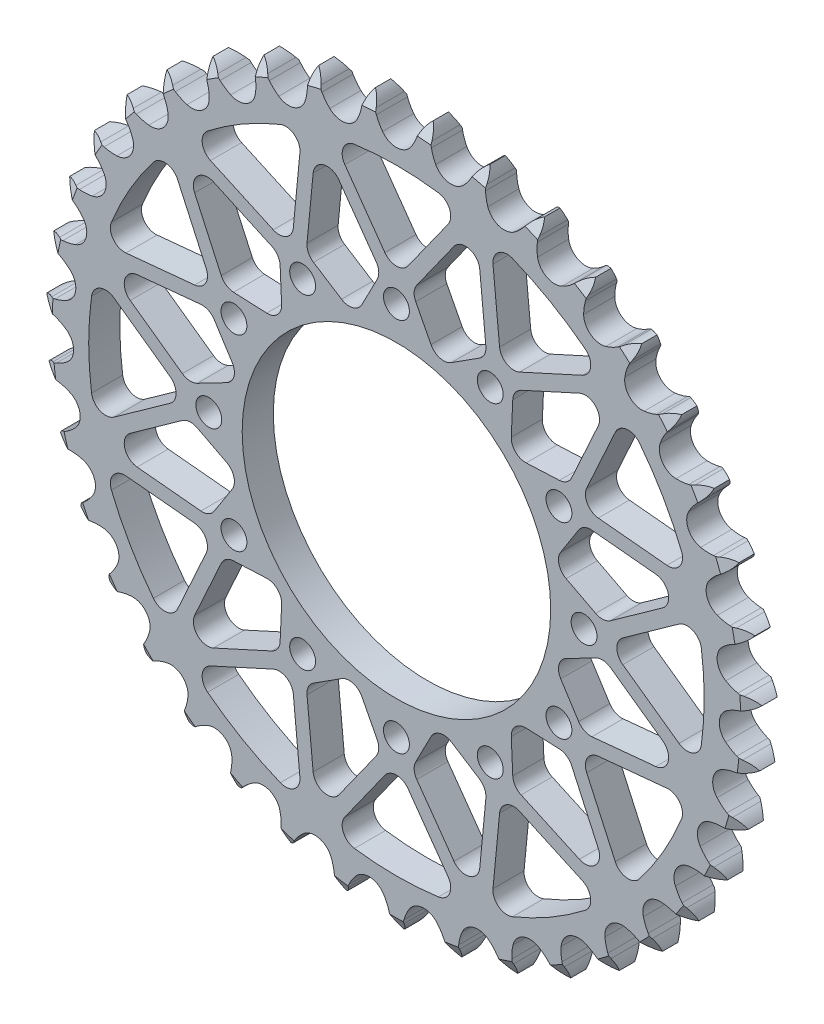
from build123d import *

# Parameters (mm, degrees)
EXTRUSION_DEPTH          = 7.2136
SKETCH1_R                = 35.764294032
CUT_EXTRUDE_DEPTH        = 1
CUT_EXTRUDE_DEPTH_BACK   = 8.2136
F_6_0MM_DOWEL_HOLE1_D    = 6
CIRPATTERN1_COUNT        = 12
CUT_EXTRUDE2_DEPTH       = 8.2136
FILLET2_R                = 3.302
CIRPATTERN3_COUNT        = 12
FILLET2_OF_CIRPATTERN3_R = 3.302


with BuildPart() as part:
    # Teeth Sketch → Extrusion (new body)
    with BuildSketch(Plane.XY):
        with BuildLine():
            ThreePointArc((6.676484762, 82.703103732), (5.710873677, 81.555589606), (5.037571935, 80.215493266))
            Line((5.037571935, 80.215493266), (4.65053543, 79.150636707))
            ThreePointArc((4.65053543, 79.150636707), (4.030589042, 77.787636082), (3.22092759, 76.5280518))
            ThreePointArc((3.22092759, 76.5280518), (0, 74.905926143), (-3.22092759, 76.5280518))
            ThreePointArc((-3.22092759, 76.5280518), (-4.030589042, 77.787636082), (-4.65053543, 79.150636707))
            Line((-4.65053543, 79.150636707), (-5.037571935, 80.215493266))
            ThreePointArc((-5.037571935, 80.215493266), (-5.710873677, 81.555589606), (-6.676484762, 82.703103732))
            ThreePointArc((-6.676484762, 82.703103732), (-7.445517227, 81.415554702), (-7.895133318, 79.984807062))
            Line((-7.895133318, 79.984807062), (-8.106342797, 78.871655094))
            ThreePointArc((-8.106342797, 78.871655094), (-8.499620367, 77.426858575), (-9.096745387, 76.053706749))
            ThreePointArc((-9.096745387, 76.053706749), (-12.015755556, 73.935914073), (-15.455180235, 75.020360508))
            ThreePointArc((-15.455180235, 75.020360508), (-16.456408311, 76.133754674), (-17.286967233, 77.379658404))
            Line((-17.286967233, 77.379658404), (-17.83980672, 78.368640329))
            ThreePointArc((-17.83980672, 78.368640329), (-18.719355953, 79.583377579), (-19.856536839, 80.561136787))
            ThreePointArc((-19.856536839, 80.561136787), (-20.409073146, 79.166899696), (-20.623358765, 77.682556369))
            Line((-20.623358765, 77.682556369), (-20.653271004, 76.549939044))
            ThreePointArc((-20.653271004, 76.549939044), (-20.809694072, 75.060766102), (-21.178817437, 73.609610642))
            ThreePointArc((-21.178817437, 73.609610642), (-23.720309356, 71.051000665), (-27.289151829, 71.569681286))
            ThreePointArc((-27.289151829, 71.569681286), (-28.456015249, 72.508049011), (-29.475675664, 73.604587595))
            Line((-29.475675664, 73.604587595), (-30.179999883, 74.492080773))
            ThreePointArc((-30.179999883, 74.492080773), (-31.243016742, 75.549997876), (-32.522315041, 76.332678717))
            ThreePointArc((-32.522315041, 76.332678717), (-32.844044791, 74.867863573), (-32.817450053, 73.368368272))
            Line((-32.817450053, 73.368368272), (-32.66529034, 72.245619783))
            ThreePointArc((-32.66529034, 72.245619783), (-32.580807632, 70.750639215), (-32.71236924, 69.259064285))
            ThreePointArc((-32.71236924, 69.259064285), (-34.810519602, 66.325903661), (-38.416348726, 66.265384911))
            ThreePointArc((-38.416348726, 66.265384911), (-39.71862634, 67.004422965), (-40.900979579, 67.923196629))
            Line((-40.900979579, 67.923196629), (-41.738546902, 68.686215454))
            ThreePointArc((-41.738546902, 68.686215454), (-42.957499809, 69.559912912), (-44.345782367, 70.127244363))
            ThreePointArc((-44.345782367, 70.127244363), (-44.428372928, 68.629789109), (-44.161586623, 67.153977974))
            Line((-44.161586623, 67.153977974), (-43.831295815, 66.070176918))
            ThreePointArc((-43.831295815, 66.070176918), (-43.508095388, 64.608107935), (-43.398687863, 63.114744543))
            ThreePointArc((-43.398687863, 63.114744543), (-44.999155676, 59.883000591), (-48.54858237, 59.244849876))
            ThreePointArc((-48.54858237, 59.244849876), (-49.952545871, 59.765417561), (-51.266969607, 60.48263055))
            Line((-51.266969607, 60.48263055), (-52.21608748, 61.101413234))
            ThreePointArc((-52.21608748, 61.101413234), (-53.559406195, 61.768262742), (-55.020717224, 62.105551216))
            ThreePointArc((-55.020717224, 62.105551216), (-54.862029543, 60.614239157), (-54.361961296, 59.200334922))
            Line((-54.361961296, 59.200334922), (-53.862093752, 58.183551176))
            ThreePointArc((-53.862093752, 58.183551176), (-53.308546327, 56.792260597), (-52.961003266, 55.335786069))
            ThreePointArc((-52.961003266, 55.335786069), (-54.022337255, 51.889159262), (-57.423433231, 50.689904348))
            ThreePointArc((-57.423433231, 50.689904348), (-58.892720703, 50.978519235), (-60.305172051, 51.475596109))
            Line((-60.305172051, 51.475596109), (-61.34125882, 51.934116506))
            ThreePointArc((-61.34125882, 51.934116506), (-62.774152094, 52.376847013), (-64.270644405, 52.475356916))
            ThreePointArc((-64.270644405, 52.475356916), (-63.87478841, 51.02881225), (-63.154389727, 49.713434291))
            Line((-63.154389727, 49.713434291), (-62.497891753, 48.790002021))
            ThreePointArc((-62.497891753, 48.790002021), (-61.728333918, 47.505523541), (-61.151656504, 46.123659804))
            ThreePointArc((-61.151656504, 46.123659804), (-61.646368676, 42.551415963), (-64.811047336, 40.822116924))
            ThreePointArc((-64.811047336, 40.822116924), (-66.307605004, 40.871304038), (-67.781502216, 41.135370767))
            Line((-67.781502216, 41.135370767), (-68.877723777, 41.42175344))
            ThreePointArc((-68.877723777, 41.42175344), (-70.363080428, 41.628898458), (-71.855995657, 41.486078435))
            ThreePointArc((-71.855995657, 41.486078435), (-71.23322381, 40.12176591), (-70.311152637, 38.938981826))
            Line((-70.311152637, 38.938981826), (-69.515027187, 38.132817442))
            ThreePointArc((-69.515027187, 38.132817442), (-68.549390085, 36.988418379), (-67.75851396, 35.716954977))
            ThreePointArc((-67.75851396, 35.716954977), (-67.673791529, 32.111613343), (-70.520089358, 29.897058114))
            ThreePointArc((-70.520089358, 29.897058114), (-72.005157166, 29.705543536), (-73.502327078, 29.729760931))
            Line((-73.502327078, 29.729760931), (-74.630291869, 29.836588719))
            ThreePointArc((-74.630291869, 29.836588719), (-76.129641939, 29.8027833), (-77.580314364, 29.422332315))
            ThreePointArc((-77.580314364, 29.422332315), (-76.74675613, 28.175586908), (-75.646893627, 27.156030185))
            Line((-75.646893627, 27.156030185), (-74.731759931, 26.488012922))
            ThreePointArc((-74.731759931, 26.488012922), (-73.595053056, 25.51333261), (-72.610461496, 24.385199777))
            ThreePointArc((-72.610461496, 24.385199777), (-71.948498729, 20.840136804), (-74.402698108, 18.197681204))
            ThreePointArc((-74.402698108, 18.197681204), (-75.837813579, 17.77042506), (-77.319480277, 17.554165902))
            Line((-77.319480277, 17.554165902), (-78.449974603, 17.478672021))
            ThreePointArc((-78.449974603, 17.478672021), (-79.924485713, 17.204791709), (-81.295343681, 16.596563242))
            ThreePointArc((-81.295343681, 16.596563242), (-80.27258778, 15.499675005), (-79.023419807, 14.669751627))
            Line((-79.023419807, 14.669751627), (-78.012979347, 14.15718278))
            ThreePointArc((-78.012979347, 14.15718278), (-76.734642811, 13.377464928), (-75.58183622, 12.421880712))
            ThreePointArc((-75.58183622, 12.421880712), (-74.359777605, 9.028911669), (-76.358316059, 6.026993909))
            ThreePointArc((-76.358316059, 6.026993909), (-77.706310456, 5.375061909), (-79.134099551, 4.923927198))
            Line((-79.134099551, 4.923927198), (-80.237844202, 4.6680669))
            ThreePointArc((-80.237844202, 4.6680669), (-81.649327289, 4.161205049), (-82.904866299, 3.340951899))
            ThreePointArc((-82.904866299, 3.340951899), (-81.719401571, 2.422329661), (-80.353280924, 1.803534207))
            Line((-80.353280924, 1.803534207), (-79.273703577, 1.45968904))
            ThreePointArc((-79.273703577, 1.45968904), (-77.886845624, 0.895127931), (-76.595681088, 0.136841462))
            ThreePointArc((-76.595681088, 0.136841462), (-74.8451773, -3.016157536), (-76.336293733, -6.299789363))
            ThreePointArc((-76.336293733, -6.299789363), (-77.56225471, -7.159512522), (-78.899187214, -7.833838635))
            Line((-78.899187214, -7.833838635), (-79.947595784, -8.263438702))
            ThreePointArc((-79.947595784, -8.263438702), (-81.259494176, -8.990154635), (-82.367196428, -10.001188343))
            ThreePointArc((-82.367196428, -10.001188343), (-81.049725787, -10.717752749), (-79.602034272, -11.109393802))
            Line((-79.602034272, -11.109393802), (-78.481280524, -11.275609878))
            ThreePointArc((-78.481280524, -11.275609878), (-77.021820047, -11.610392409), (-75.625738049, -12.151741911))
            ThreePointArc((-75.625738049, -12.151741911), (-73.392126218, -14.983109845), (-74.337201497, -18.463411399))
            ThreePointArc((-74.337201497, -18.463411399), (-75.409377308, -19.50865934), (-76.620827372, -20.388712162))
            Line((-76.620827372, -20.388712162), (-77.586746629, -20.980925582))
            ThreePointArc((-77.586746629, -20.980925582), (-78.765082849, -21.908674036), (-79.696259435, -23.08430306))
            ThreePointArc((-79.696259435, -23.08430306), (-78.280904679, -23.580250992), (-76.789136745, -23.734594346))
            Line((-76.789136745, -23.734594346), (-75.656233531, -23.718876424))
            ThreePointArc((-75.656233531, -23.718876424), (-74.161969788, -23.815209685), (-72.697128119, -24.125601551))
            ThreePointArc((-72.697128119, -24.125601551), (-70.038257617, -26.562007479), (-70.41281479, -30.148840778))
            ThreePointArc((-70.41281479, -30.148840778), (-71.303436645, -31.352542128), (-72.358028349, -32.415528753))
            Line((-72.358028349, -32.415528753), (-73.216441492, -33.155017511))
            ThreePointArc((-73.216441492, -33.155017511), (-74.230697248, -34.259770288), (-74.961231185, -35.569546454))
            ThreePointArc((-74.961231185, -35.569546454), (-73.484649258, -35.832033121), (-71.987440912, -35.745081364))
            Line((-71.987440912, -35.745081364), (-70.871729829, -35.547836529))
            ThreePointArc((-70.871729829, -35.547836529), (-69.381363468, -35.403225539), (-67.885700756, -35.474620783))
            ThreePointArc((-67.885700756, -35.474620783), (-64.870434934, -37.452963072), (-64.664773166, -41.053431017))
            ThreePointArc((-64.664773166, -41.053431017), (-65.350774426, -42.384410543), (-66.221194398, -43.602800177))
            Line((-66.221194398, -43.602800177), (-66.949868978, -44.470411902))
            ThreePointArc((-66.949868978, -44.470411902), (-67.773775581, -45.723556485), (-68.284746423, -47.133557278))
            ThreePointArc((-68.284746423, -47.133557278), (-66.785180021, -47.155784414), (-65.321308173, -46.829789551))
            Line((-65.321308173, -46.829789551), (-64.251685552, -46.456126341))
            ThreePointArc((-64.251685552, -46.456126341), (-62.803816278, -46.074316448), (-61.316069403, -45.904865971))
            ThreePointArc((-61.316069403, -45.904865971), (-58.022502061, -47.373906594), (-57.241947884, -50.894758957))
            ThreePointArc((-57.241947884, -50.894758957), (-57.705561477, -52.318544989), (-58.369266298, -53.66078198))
            Line((-58.369266298, -53.66078198), (-58.949330025, -54.634045983))
            ThreePointArc((-58.949330025, -54.634045983), (-59.561548726, -56.003126587), (-59.839722596, -57.476833727))
            ThreePointArc((-59.839722596, -57.476833727), (-58.356009703, -57.25822566), (-56.963387864, -56.701630787))
            Line((-56.963387864, -56.701630787), (-55.967556369, -56.161226883))
            ThreePointArc((-55.967556369, -56.161226883), (-54.599683236, -55.552106762), (-53.15838406, -55.146199243))
            ThreePointArc((-53.15838406, -55.146199243), (-49.671816862, -56.06789082), (-48.336586219, -59.417939375))
            ThreePointArc((-48.336586219, -59.417939375), (-48.565804798, -60.897656602), (-49.00560486, -62.328977716))
            Line((-49.00560486, -62.328977716), (-49.422034389, -63.382686971))
            ThreePointArc((-49.422034389, -63.382686971), (-49.806709045, -64.832245127), (-49.844881387, -66.331490374))
            ThreePointArc((-49.844881387, -66.331490374), (-48.415449386, -65.877708938), (-47.130145731, -65.104929569))
            Line((-47.130145731, -65.104929569), (-46.233896874, -64.411781148))
            ThreePointArc((-46.233896874, -64.411781148), (-44.981447078, -63.591126692), (-43.623924493, -62.959274922))
            ThreePointArc((-43.623924493, -62.959274922), (-40.034657698, -63.309746125), (-38.179332362, -66.402226373))
            ThreePointArc((-38.179332362, -66.402226373), (-38.168219284, -67.899550896), (-38.372723998, -69.38288567))
            Line((-38.372723998, -69.38288567), (-38.614734022, -70.489749661))
            ThreePointArc((-38.614734022, -70.489749661), (-38.761901763, -71.982242573), (-38.559083932, -73.468196262))
            ThreePointArc((-38.559083932, -73.468196262), (-37.220954361, -72.790994159), (-36.076257579, -71.822044874))
            Line((-36.076257579, -71.822044874), (-35.302803736, -70.994104116))
            ThreePointArc((-35.302803736, -70.994104116), (-34.198215068, -69.983169844), (-32.959628196, -69.141738451))
            ThreePointArc((-32.959628196, -69.141738451), (-29.360621929, -68.91191226), (-27.033253851, -71.666730588))
            ThreePointArc((-27.033253851, -71.666730588), (-26.78209694, -73.142882488), (-26.74600974, -74.639813329))
            Line((-26.74600974, -74.639813329), (-26.807332328, -75.77116486))
            ThreePointArc((-26.807332328, -75.77116486), (-26.713181585, -77.267937748), (-26.274626458, -78.702114459))
            ThreePointArc((-26.274626458, -78.702114459), (-25.06245617, -77.819030866), (-24.088013307, -76.679006943))
            Line((-24.088013307, -76.679006943), (-23.457386525, -75.737717079))
            ThreePointArc((-23.457386525, -75.737717079), (-22.529267252, -74.562685657), (-21.441694841, -73.533467273))
            ThreePointArc((-21.441694841, -73.533467273), (-17.926161474, -72.729296065), (-15.187028265, -75.075104125))
            ThreePointArc((-15.187028265, -75.075104125), (-14.702332353, -76.491851845), (-14.426587879, -77.96360903))
            Line((-14.426587879, -77.96360903), (-14.305634807, -79.090146691))
            ThreePointArc((-14.305634807, -79.090146691), (-13.972604036, -80.552433921), (-13.309669959, -81.897689231))
            ThreePointArc((-13.309669959, -81.897689231), (-12.254853529, -80.83159555), (-11.475902142, -79.55002301))
            Line((-11.475902142, -79.55002301), (-11.004435324, -78.519762952))
            ThreePointArc((-11.004435324, -78.519762952), (-10.276823247, -77.211067077), (-9.368432854, -76.020717918))
            ThreePointArc((-9.368432854, -76.020717918), (-6.027422853, -74.663029306), (-2.947466624, -76.5390719))
            ThreePointArc((-2.947466624, -76.5390719), (-2.241785081, -77.859722417), (-1.733524971, -79.26818821))
            Line((-1.733524971, -79.26818821), (-1.43342886, -80.360735266))
            ThreePointArc((-1.43342886, -80.360735266), (-0.870143382, -81.750664368), (0, -82.97215687))
            ThreePointArc((0, -82.97215687), (0.870143382, -81.750664368), (1.43342886, -80.360735266))
            Line((1.43342886, -80.360735266), (1.733524971, -79.26818821))
            ThreePointArc((1.733524971, -79.26818821), (2.241785081, -77.859722417), (2.947466624, -76.5390719))
            ThreePointArc((2.947466624, -76.5390719), (6.027422853, -74.663029306), (9.368432854, -76.020717918))
            ThreePointArc((9.368432854, -76.020717918), (10.276823247, -77.211067077), (11.004435324, -78.519762952))
            Line((11.004435324, -78.519762952), (11.475902142, -79.55002301))
            ThreePointArc((11.475902142, -79.55002301), (12.254853529, -80.83159555), (13.309669959, -81.897689231))
            ThreePointArc((13.309669959, -81.897689231), (13.972604036, -80.552433921), (14.305634807, -79.090146691))
            Line((14.305634807, -79.090146691), (14.426587879, -77.96360903))
            ThreePointArc((14.426587879, -77.96360903), (14.702332353, -76.491851845), (15.187028265, -75.075104125))
            ThreePointArc((15.187028265, -75.075104125), (17.926161474, -72.729296065), (21.441694841, -73.533467273))
            ThreePointArc((21.441694841, -73.533467273), (22.529267252, -74.562685657), (23.457386525, -75.737717079))
            Line((23.457386525, -75.737717079), (24.088013307, -76.679006943))
            ThreePointArc((24.088013307, -76.679006943), (25.06245617, -77.819030866), (26.274626458, -78.702114459))
            ThreePointArc((26.274626458, -78.702114459), (26.713181585, -77.267937748), (26.807332328, -75.77116486))
            Line((26.807332328, -75.77116486), (26.74600974, -74.639813329))
            ThreePointArc((26.74600974, -74.639813329), (26.78209694, -73.142882488), (27.033253851, -71.666730588))
            ThreePointArc((27.033253851, -71.666730588), (29.360621929, -68.91191226), (32.959628196, -69.141738451))
            ThreePointArc((32.959628196, -69.141738451), (34.198215068, -69.983169844), (35.302803736, -70.994104116))
            Line((35.302803736, -70.994104116), (36.076257579, -71.822044874))
            ThreePointArc((36.076257579, -71.822044874), (37.220954361, -72.790994159), (38.559083932, -73.468196262))
            ThreePointArc((38.559083932, -73.468196262), (38.761901763, -71.982242573), (38.614734022, -70.489749661))
            Line((38.614734022, -70.489749661), (38.372723998, -69.38288567))
            ThreePointArc((38.372723998, -69.38288567), (38.168219284, -67.899550896), (38.179332362, -66.402226373))
            ThreePointArc((38.179332362, -66.402226373), (40.034657698, -63.309746125), (43.623924493, -62.959274922))
            ThreePointArc((43.623924493, -62.959274922), (44.981447078, -63.591126692), (46.233896874, -64.411781148))
            Line((46.233896874, -64.411781148), (47.130145731, -65.104929569))
            ThreePointArc((47.130145731, -65.104929569), (48.415449386, -65.877708938), (49.844881387, -66.331490374))
            ThreePointArc((49.844881387, -66.331490374), (49.806709045, -64.832245127), (49.422034389, -63.382686971))
            Line((49.422034389, -63.382686971), (49.00560486, -62.328977716))
            ThreePointArc((49.00560486, -62.328977716), (48.565804798, -60.897656602), (48.336586219, -59.417939375))
            ThreePointArc((48.336586219, -59.417939375), (49.671816862, -56.06789082), (53.15838406, -55.146199243))
            ThreePointArc((53.15838406, -55.146199243), (54.599683236, -55.552106762), (55.967556369, -56.161226883))
            Line((55.967556369, -56.161226883), (56.963387864, -56.701630787))
            ThreePointArc((56.963387864, -56.701630787), (58.356009703, -57.25822566), (59.839722596, -57.476833727))
            ThreePointArc((59.839722596, -57.476833727), (59.561548726, -56.003126587), (58.949330025, -54.634045983))
            Line((58.949330025, -54.634045983), (58.369266298, -53.66078198))
            ThreePointArc((58.369266298, -53.66078198), (57.705561477, -52.318544989), (57.241947884, -50.894758957))
            ThreePointArc((57.241947884, -50.894758957), (58.022502061, -47.373906594), (61.316069403, -45.904865971))
            ThreePointArc((61.316069403, -45.904865971), (62.803816278, -46.074316448), (64.251685552, -46.456126341))
            Line((64.251685552, -46.456126341), (65.321308173, -46.829789551))
            ThreePointArc((65.321308173, -46.829789551), (66.785180021, -47.155784414), (68.284746423, -47.133557278))
            ThreePointArc((68.284746423, -47.133557278), (67.773775581, -45.723556485), (66.949868978, -44.470411902))
            Line((66.949868978, -44.470411902), (66.221194398, -43.602800177))
            ThreePointArc((66.221194398, -43.602800177), (65.350774426, -42.384410543), (64.664773166, -41.053431017))
            ThreePointArc((64.664773166, -41.053431017), (64.870434934, -37.452963072), (67.885700756, -35.474620783))
            ThreePointArc((67.885700756, -35.474620783), (69.381363468, -35.403225539), (70.871729829, -35.547836529))
            Line((70.871729829, -35.547836529), (71.987440912, -35.745081364))
            ThreePointArc((71.987440912, -35.745081364), (73.484649258, -35.832033121), (74.961231185, -35.569546454))
            ThreePointArc((74.961231185, -35.569546454), (74.230697248, -34.259770288), (73.216441492, -33.155017511))
            Line((73.216441492, -33.155017511), (72.358028349, -32.415528753))
            ThreePointArc((72.358028349, -32.415528753), (71.303436645, -31.352542128), (70.41281479, -30.148840778))
            ThreePointArc((70.41281479, -30.148840778), (70.038257617, -26.562007479), (72.697128119, -24.125601551))
            ThreePointArc((72.697128119, -24.125601551), (74.161969788, -23.815209685), (75.656233531, -23.718876424))
            Line((75.656233531, -23.718876424), (76.789136745, -23.734594346))
            ThreePointArc((76.789136745, -23.734594346), (78.280904679, -23.580250992), (79.696259435, -23.08430306))
            ThreePointArc((79.696259435, -23.08430306), (78.765082849, -21.908674036), (77.586746629, -20.980925582))
            Line((77.586746629, -20.980925582), (76.620827372, -20.388712162))
            ThreePointArc((76.620827372, -20.388712162), (75.409377308, -19.50865934), (74.337201497, -18.463411399))
            ThreePointArc((74.337201497, -18.463411399), (73.392126218, -14.983109845), (75.625738049, -12.151741911))
            ThreePointArc((75.625738049, -12.151741911), (77.021820047, -11.610392409), (78.481280524, -11.275609878))
            Line((78.481280524, -11.275609878), (79.602034272, -11.109393802))
            ThreePointArc((79.602034272, -11.109393802), (81.049725787, -10.717752749), (82.367196428, -10.001188343))
            ThreePointArc((82.367196428, -10.001188343), (81.259494176, -8.990154635), (79.947595784, -8.263438702))
            Line((79.947595784, -8.263438702), (78.899187214, -7.833838635))
            ThreePointArc((78.899187214, -7.833838635), (77.56225471, -7.159512522), (76.336293733, -6.299789363))
            ThreePointArc((76.336293733, -6.299789363), (74.8451773, -3.016157536), (76.595681088, 0.136841462))
            ThreePointArc((76.595681088, 0.136841462), (77.886845624, 0.895127931), (79.273703577, 1.45968904))
            Line((79.273703577, 1.45968904), (80.353280924, 1.803534207))
            ThreePointArc((80.353280924, 1.803534207), (81.719401571, 2.422329661), (82.904866299, 3.340951899))
            ThreePointArc((82.904866299, 3.340951899), (81.649327289, 4.161205049), (80.237844202, 4.6680669))
            Line((80.237844202, 4.6680669), (79.134099551, 4.923927198))
            ThreePointArc((79.134099551, 4.923927198), (77.706310456, 5.375061909), (76.358316059, 6.026993909))
            ThreePointArc((76.358316059, 6.026993909), (74.359777605, 9.028911669), (75.58183622, 12.421880712))
            ThreePointArc((75.58183622, 12.421880712), (76.734642811, 13.377464928), (78.012979347, 14.15718278))
            Line((78.012979347, 14.15718278), (79.023419807, 14.669751627))
            ThreePointArc((79.023419807, 14.669751627), (80.27258778, 15.499675005), (81.295343681, 16.596563242))
            ThreePointArc((81.295343681, 16.596563242), (79.924485713, 17.204791709), (78.449974603, 17.478672021))
            Line((78.449974603, 17.478672021), (77.319480277, 17.554165902))
            ThreePointArc((77.319480277, 17.554165902), (75.837813579, 17.77042506), (74.402698108, 18.197681204))
            ThreePointArc((74.402698108, 18.197681204), (71.948498729, 20.840136804), (72.610461496, 24.385199777))
            ThreePointArc((72.610461496, 24.385199777), (73.595053056, 25.51333261), (74.731759931, 26.488012922))
            Line((74.731759931, 26.488012922), (75.646893627, 27.156030185))
            ThreePointArc((75.646893627, 27.156030185), (76.74675613, 28.175586908), (77.580314364, 29.422332315))
            ThreePointArc((77.580314364, 29.422332315), (76.129641939, 29.8027833), (74.630291869, 29.836588719))
            Line((74.630291869, 29.836588719), (73.502327078, 29.729760931))
            ThreePointArc((73.502327078, 29.729760931), (72.005157166, 29.705543536), (70.520089358, 29.897058114))
            ThreePointArc((70.520089358, 29.897058114), (67.673791529, 32.111613343), (67.75851396, 35.716954977))
            ThreePointArc((67.75851396, 35.716954977), (68.549390085, 36.988418379), (69.515027187, 38.132817442))
            Line((69.515027187, 38.132817442), (70.311152637, 38.938981826))
            ThreePointArc((70.311152637, 38.938981826), (71.23322381, 40.12176591), (71.855995657, 41.486078435))
            ThreePointArc((71.855995657, 41.486078435), (70.363080428, 41.628898458), (68.877723777, 41.42175344))
            Line((68.877723777, 41.42175344), (67.781502216, 41.135370767))
            ThreePointArc((67.781502216, 41.135370767), (66.307605004, 40.871304038), (64.811047336, 40.822116924))
            ThreePointArc((64.811047336, 40.822116924), (61.646368676, 42.551415963), (61.151656504, 46.123659804))
            ThreePointArc((61.151656504, 46.123659804), (61.728333918, 47.505523541), (62.497891753, 48.790002021))
            Line((62.497891753, 48.790002021), (63.154389727, 49.713434291))
            ThreePointArc((63.154389727, 49.713434291), (63.87478841, 51.02881225), (64.270644405, 52.475356916))
            ThreePointArc((64.270644405, 52.475356916), (62.774152094, 52.376847013), (61.34125882, 51.934116506))
            Line((61.34125882, 51.934116506), (60.305172051, 51.475596109))
            ThreePointArc((60.305172051, 51.475596109), (58.892720703, 50.978519235), (57.423433231, 50.689904348))
            ThreePointArc((57.423433231, 50.689904348), (54.022337255, 51.889159262), (52.961003266, 55.335786069))
            ThreePointArc((52.961003266, 55.335786069), (53.308546327, 56.792260597), (53.862093752, 58.183551176))
            Line((53.862093752, 58.183551176), (54.361961296, 59.200334922))
            ThreePointArc((54.361961296, 59.200334922), (54.862029543, 60.614239157), (55.020717224, 62.105551216))
            ThreePointArc((55.020717224, 62.105551216), (53.559406195, 61.768262742), (52.21608748, 61.101413234))
            Line((52.21608748, 61.101413234), (51.266969607, 60.48263055))
            ThreePointArc((51.266969607, 60.48263055), (49.952545871, 59.765417561), (48.54858237, 59.244849876))
            ThreePointArc((48.54858237, 59.244849876), (44.999155676, 59.883000591), (43.398687863, 63.114744543))
            ThreePointArc((43.398687863, 63.114744543), (43.508095388, 64.608107935), (43.831295815, 66.070176918))
            Line((43.831295815, 66.070176918), (44.161586623, 67.153977974))
            ThreePointArc((44.161586623, 67.153977974), (44.428372928, 68.629789109), (44.345782367, 70.127244363))
            ThreePointArc((44.345782367, 70.127244363), (42.957499809, 69.559912912), (41.738546902, 68.686215454))
            Line((41.738546902, 68.686215454), (40.900979579, 67.923196629))
            ThreePointArc((40.900979579, 67.923196629), (39.71862634, 67.004422965), (38.416348726, 66.265384911))
            ThreePointArc((38.416348726, 66.265384911), (34.810519602, 66.325903661), (32.71236924, 69.259064285))
            ThreePointArc((32.71236924, 69.259064285), (32.580807632, 70.750639215), (32.66529034, 72.245619783))
            Line((32.66529034, 72.245619783), (32.817450053, 73.368368272))
            ThreePointArc((32.817450053, 73.368368272), (32.844044791, 74.867863573), (32.522315041, 76.332678717))
            ThreePointArc((32.522315041, 76.332678717), (31.243016742, 75.549997876), (30.179999883, 74.492080773))
            Line((30.179999883, 74.492080773), (29.475675664, 73.604587595))
            ThreePointArc((29.475675664, 73.604587595), (28.456015249, 72.508049011), (27.289151829, 71.569681286))
            ThreePointArc((27.289151829, 71.569681286), (23.720309356, 71.051000665), (21.178817437, 73.609610642))
            ThreePointArc((21.178817437, 73.609610642), (20.809694072, 75.060766102), (20.653271004, 76.549939044))
            Line((20.653271004, 76.549939044), (20.623358765, 77.682556369))
            ThreePointArc((20.623358765, 77.682556369), (20.409073146, 79.166899696), (19.856536839, 80.561136787))
            ThreePointArc((19.856536839, 80.561136787), (18.719355953, 79.583377579), (17.83980672, 78.368640329))
            Line((17.83980672, 78.368640329), (17.286967233, 77.379658404))
            ThreePointArc((17.286967233, 77.379658404), (16.456408311, 76.133754674), (15.455180235, 75.020360508))
            ThreePointArc((15.455180235, 75.020360508), (12.015755556, 73.935914073), (9.096745387, 76.053706749))
            ThreePointArc((9.096745387, 76.053706749), (8.499620367, 77.426858575), (8.106342797, 78.871655094))
            Line((8.106342797, 78.871655094), (7.895133318, 79.984807062))
            ThreePointArc((7.895133318, 79.984807062), (7.445517227, 81.415554702), (6.676484762, 82.703103732))
        make_face()
    extrude(amount=EXTRUSION_DEPTH)

    # Sketch1 → Cut-Extrude (cut, two sides)
    with BuildSketch(Plane(origin=(0, 0, 0), x_dir=(-1, 0, 0), z_dir=(0, 0, -1))) as cut_extrude_sk:
        Circle(SKETCH1_R)
    extrude(amount=CUT_EXTRUDE_DEPTH, mode=Mode.SUBTRACT)
    extrude(cut_extrude_sk.sketch, amount=-CUT_EXTRUDE_DEPTH_BACK, mode=Mode.SUBTRACT)

    # 6.0mm Dowel Hole1 (through all)
    with Locations(Plane.XY.offset(7.2136)):
        with Locations((-43.500000122, 0)):
            f_6_0mm_dowel_hole1 = Hole(F_6_0MM_DOWEL_HOLE1_D / 2)

    # CirPattern1: 6.0mm Dowel Hole1 ×12 about axis
    cirpattern1_axis = Axis((0, 0, 0), (0, 0, 1))
    for i in range(1, CIRPATTERN1_COUNT):
        add(f_6_0mm_dowel_hole1.rotate(cirpattern1_axis, i * 360 / CIRPATTERN1_COUNT), mode=Mode.SUBTRACT)

    # Sketch9 → Cut-Extrude2 (cut, through all)
    with BuildSketch(Plane.XY):
        with BuildLine():
            Line((-48.707000122, 0), (-69.753908506, 15.006805414))
            ThreePointArc((-69.753908506, 15.006805414), (-71.349926143, 0), (-69.753908506, -15.006805414))
            Line((-69.753908506, -15.006805414), (-48.707000122, 0))
        make_face()
        Polygon((-47.983941179, 3.539852965), (-68.918736366, 18.466719753), (-43.325238517, 20.926367996), (-36.140398804, 9.683790674), align=None)
    cut_extrude2 = extrude(amount=CUT_EXTRUDE2_DEPTH, mode=Mode.SUBTRACT)

    # Fillet2
    fillet2_edges = [part.edges().sort_by_distance(p)[0] for p in [
        (-68.918736366, 18.466719753, 3.6068),
        (-47.983941179, 3.539852965, 3.6068),
        (-36.140398804, 9.683790674, 3.6068),
        (-43.325238517, 20.926367996, 3.6068),
        (-48.707000122, 0, 3.6068),
        (-69.753908506, 15.006805414, 3.6068),
        (-69.753908506, -15.006805414, 3.6068),
    ]]
    fillet(fillet2_edges, radius=FILLET2_R)

    # CirPattern3: Cut-Extrude2 ×12 about axis
    cirpattern3_axis = Axis((0, 0, 0), (0, 0, 1))
    for i in range(1, CIRPATTERN3_COUNT):
        add(cut_extrude2.rotate(cirpattern3_axis, i * 360 / CIRPATTERN3_COUNT), mode=Mode.SUBTRACT)

    # Fillet2 of CirPattern3
    fillet2_of_cirpattern3_edges = [part.edges().sort_by_distance(p)[0] for p in [
        (-68.918736366, -18.466719753, 3.6068),
        (-43.325238517, -20.926367996, 3.6068),
        (-36.140398804, -9.683790674, 3.6068),
        (-47.983941179, -3.539852965, 3.6068),
        (-42.181499448, -24.353500061, 3.6068),
        (-67.912059487, -21.880679535, 3.6068),
        (-52.905254073, -47.873228971, 3.6068),
        (-50.452016613, -50.452016613, 3.6068),
        (-27.057573183, -39.785385552, 3.6068),
        (-26.45660813, -26.45660813, 3.6068),
        (-39.785385552, -27.057573183, 3.6068),
        (-24.353500061, -42.181499448, 3.6068),
        (-47.873228971, -52.905254073, 3.6068),
        (-21.880679535, -67.912059487, 3.6068),
        (-18.466719753, -68.918736366, 3.6068),
        (-3.539852965, -47.983941179, 3.6068),
        (-9.683790674, -36.140398804, 3.6068),
        (-20.926367996, -43.325238517, 3.6068),
        (0, -48.707000122, 3.6068),
        (-15.006805414, -69.753908506, 3.6068),
        (15.006805414, -69.753908506, 3.6068),
        (18.466719753, -68.918736366, 3.6068),
        (20.926367996, -43.325238517, 3.6068),
        (9.683790674, -36.140398804, 3.6068),
        (3.539852965, -47.983941179, 3.6068),
        (24.353500061, -42.181499448, 3.6068),
        (21.880679535, -67.912059487, 3.6068),
        (47.873228971, -52.905254073, 3.6068),
        (50.452016613, -50.452016613, 3.6068),
        (39.785385552, -27.057573183, 3.6068),
        (26.45660813, -26.45660813, 3.6068),
        (27.057573183, -39.785385552, 3.6068),
        (42.181499448, -24.353500061, 3.6068),
        (52.905254073, -47.873228971, 3.6068),
        (67.912059487, -21.880679535, 3.6068),
        (68.918736366, -18.466719753, 3.6068),
        (47.983941179, -3.539852965, 3.6068),
        (36.140398804, -9.683790674, 3.6068),
        (43.325238517, -20.926367996, 3.6068),
        (48.707000122, 0, 3.6068),
        (69.753908506, -15.006805414, 3.6068),
        (69.753908506, 15.006805414, 3.6068),
        (68.918736366, 18.466719753, 3.6068),
        (43.325238517, 20.926367996, 3.6068),
        (36.140398804, 9.683790674, 3.6068),
        (47.983941179, 3.539852965, 3.6068),
        (42.181499448, 24.353500061, 3.6068),
        (67.912059487, 21.880679535, 3.6068),
        (52.905254073, 47.873228971, 3.6068),
        (50.452016613, 50.452016613, 3.6068),
        (27.057573183, 39.785385552, 3.6068),
        (26.45660813, 26.45660813, 3.6068),
        (39.785385552, 27.057573183, 3.6068),
        (24.353500061, 42.181499448, 3.6068),
        (47.873228971, 52.905254073, 3.6068),
        (21.880679535, 67.912059487, 3.6068),
        (18.466719753, 68.918736366, 3.6068),
        (3.539852965, 47.983941179, 3.6068),
        (9.683790674, 36.140398804, 3.6068),
        (20.926367996, 43.325238517, 3.6068),
        (0, 48.707000122, 3.6068),
        (15.006805414, 69.753908506, 3.6068),
        (-15.006805414, 69.753908506, 3.6068),
        (-18.466719753, 68.918736366, 3.6068),
        (-20.926367996, 43.325238517, 3.6068),
        (-9.683790674, 36.140398804, 3.6068),
        (-3.539852965, 47.983941179, 3.6068),
        (-24.353500061, 42.181499448, 3.6068),
        (-21.880679535, 67.912059487, 3.6068),
        (-47.873228971, 52.905254073, 3.6068),
        (-50.452016613, 50.452016613, 3.6068),
        (-39.785385552, 27.057573183, 3.6068),
        (-26.45660813, 26.45660813, 3.6068),
        (-27.057573183, 39.785385552, 3.6068),
        (-42.181499448, 24.353500061, 3.6068),
        (-52.905254073, 47.873228971, 3.6068),
        (-67.912059487, 21.880679535, 3.6068),
    ]]
    fillet(fillet2_of_cirpattern3_edges, radius=FILLET2_OF_CIRPATTERN3_R)

    # Sketch18 → Cut-Revolve2 (revolve, cut)
    with BuildSketch(Plane(origin=(0, 0, 0), x_dir=(0, 0, -1), z_dir=(1, 0, 0))):
        Polygon((-7.2136, -79.778574738), (-7.2136, -82.97215687), (-5.3848, -82.97215687), align=None)
    cut_revolve2 = revolve(axis=Axis((0, 0, -0.36068), (0, 0, 1)), mode=Mode.SUBTRACT)

    # Mirror1: Cut-Revolve2 across plane
    add(cut_revolve2.mirror(Plane(origin=(0, 0, 3.6068), x_dir=(1, 0, 0), z_dir=(0, 0, -1))), mode=Mode.SUBTRACT)


solid = part.part
